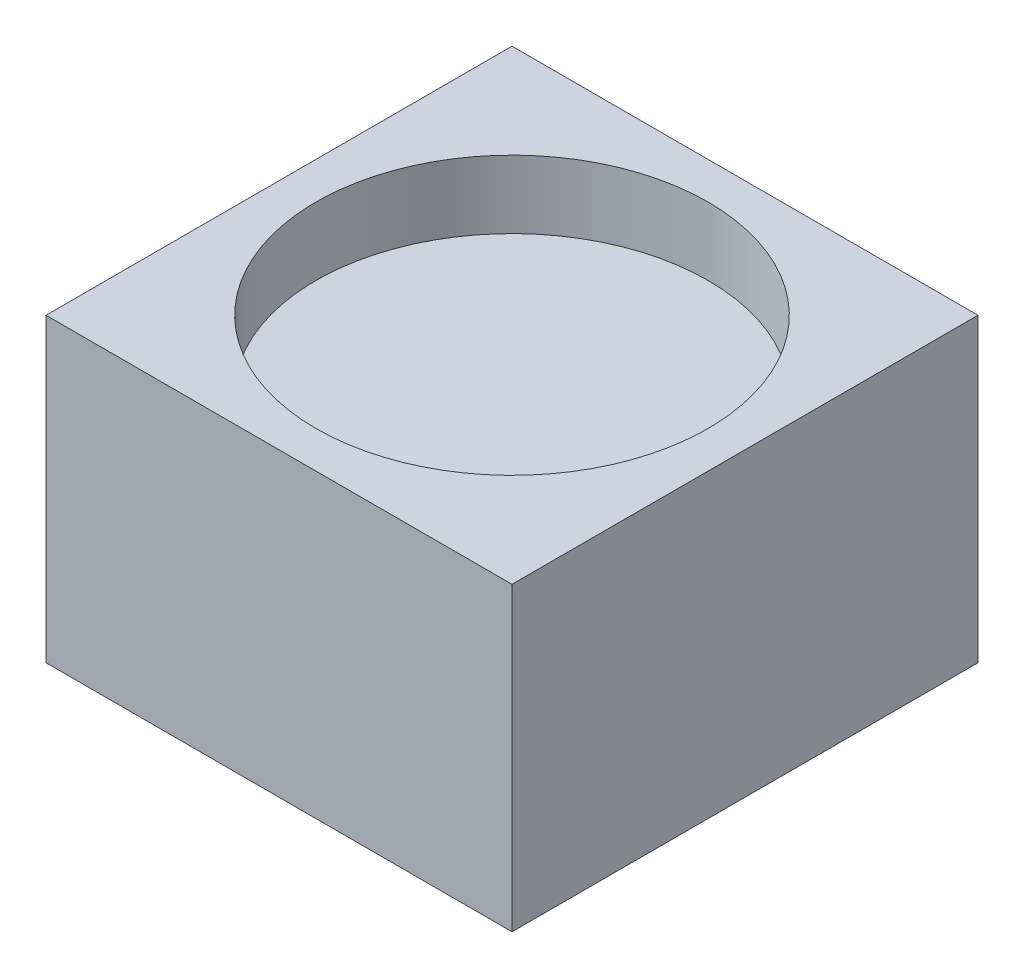
from build123d import *

# Parameters (mm, degrees)
SKETCH1_W           = 152.4
SKETCH1_H           = 152.4
SKETCH1_R           = 64.135
BOSS_EXTRUDE1_DEPTH = 22.225
SKETCH2_W           = 152.4
SKETCH2_H           = 152.4
BOSS_EXTRUDE2_DEPTH = 76.2


with BuildPart() as part:
    # Sketch1 → Boss-Extrude1 (new body)
    with BuildSketch(Plane(origin=(0, 0, 0), x_dir=(1, 0, 0), z_dir=(0, 1, 0))):
        Rectangle(SKETCH1_W, SKETCH1_H)
        Circle(SKETCH1_R, mode=Mode.SUBTRACT)
    extrude(amount=BOSS_EXTRUDE1_DEPTH)

    # Sketch2 → Boss-Extrude2 (add)
    with BuildSketch(Plane(origin=(0, 0, 0), x_dir=(-1, 0, 0), z_dir=(0, -1, 0))):
        Rectangle(SKETCH2_W, SKETCH2_H)
    extrude(amount=BOSS_EXTRUDE2_DEPTH)


solid = part.part
